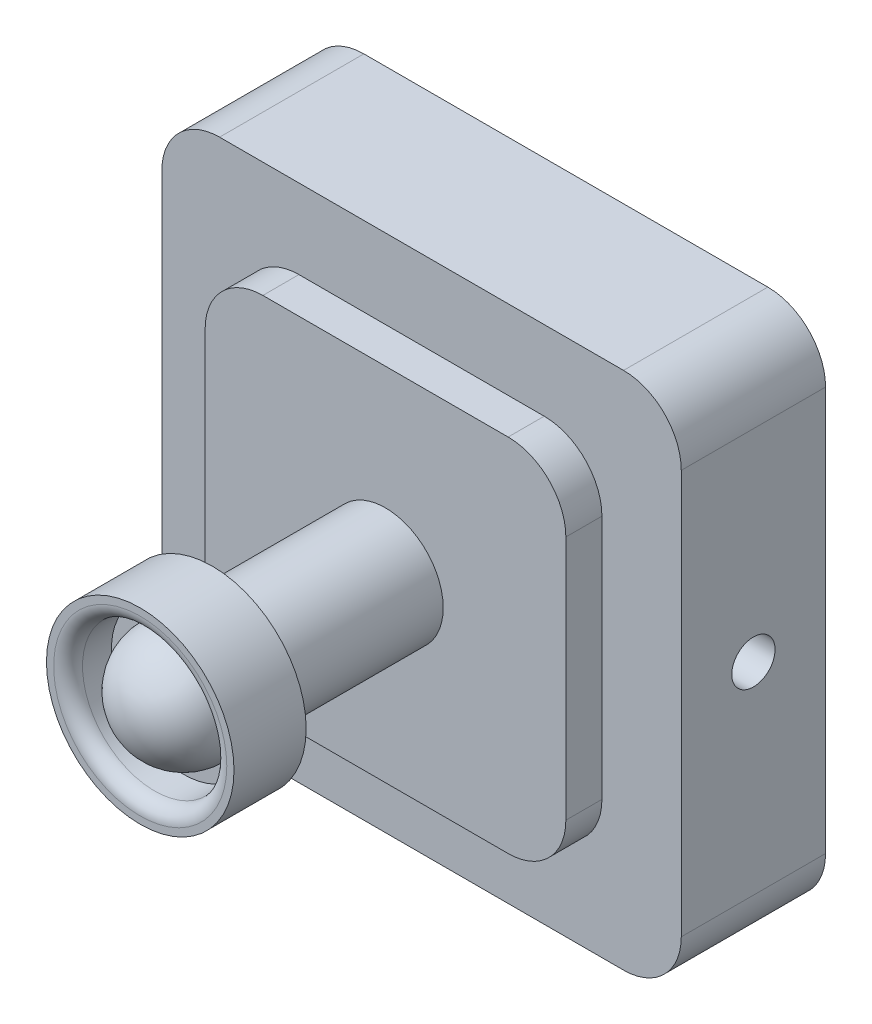
from build123d import *

# Parameters (mm, degrees)
SKETCH1_W           = 36
SKETCH1_H           = 36
BOSS_EXTRUDE1_DEPTH = 10
SKETCH2_W           = 25
SKETCH2_H           = 25
BOSS_EXTRUDE2_DEPTH = 2.5
SKETCH3_R           = 4
BOSS_EXTRUDE3_DEPTH = 12
SKETCH4_R           = 6.5
BOSS_EXTRUDE4_DEPTH = 5
SKETCH5_R           = 5
CUT_EXTRUDE1_DEPTH  = 3
FILLET1_R           = 4
FILLET2_R           = 4
SKETCH7_R           = 1.5
CUT_EXTRUDE2_DEPTH  = 5
SKETCH8_R           = 1.5
CUT_EXTRUDE3_DEPTH  = 5
FILLET3_R           = 1


with BuildPart() as part:
    # Sketch1 → Boss-Extrude1 (new body)
    with BuildSketch(Plane.XY):
        with Locations((18, 18)):
            Rectangle(SKETCH1_W, SKETCH1_H)
    extrude(amount=BOSS_EXTRUDE1_DEPTH)

    # Sketch2 → Boss-Extrude2 (add)
    with BuildSketch(Plane.XY.offset(10)):
        with Locations((18, 18)):
            Rectangle(SKETCH2_W, SKETCH2_H)
    extrude(amount=BOSS_EXTRUDE2_DEPTH)

    # Sketch3 → Boss-Extrude3 (add)
    with BuildSketch(Plane.XY.offset(12.5)):
        with Locations((18, 18)):
            Circle(SKETCH3_R)
    extrude(amount=BOSS_EXTRUDE3_DEPTH)

    # Sketch4 → Boss-Extrude4 (add)
    with BuildSketch(Plane.XY.offset(24.5)):
        with Locations((18, 18)):
            Circle(SKETCH4_R)
    extrude(amount=BOSS_EXTRUDE4_DEPTH)

    # Sketch5 → Cut-Extrude1 (cut)
    with BuildSketch(Plane.XY.offset(29.5)):
        with Locations((18, 18)):
            Circle(SKETCH5_R)
    extrude(amount=-CUT_EXTRUDE1_DEPTH, mode=Mode.SUBTRACT)

    # Sketch6 → Revolve4 (revolve)
    with BuildSketch(Plane.XY.offset(26.5)):
        with BuildLine():
            Line((18, 22), (18, 14))
            ThreePointArc((18, 14), (22, 18), (18, 22))
        make_face()
    revolve(axis=Axis((18, 22, 26.5), (0, -1, 0)))

    # Fillet1
    fillet1_edges = [part.edges().sort_by_distance(p)[0] for p in [
        (30.5, 5.5, 11.25),
        (30.5, 30.5, 11.25),
        (5.5, 30.5, 11.25),
        (5.5, 5.5, 11.25),
    ]]
    fillet(fillet1_edges, radius=FILLET1_R)

    # Fillet2
    fillet2_edges = [part.edges().sort_by_distance(p)[0] for p in [
        (0, 36, 5),
        (36, 36, 5),
        (36, 0, 5),
        (0, 0, 5),
    ]]
    fillet(fillet2_edges, radius=FILLET2_R)

    # Sketch7 → Cut-Extrude2 (cut)
    with BuildSketch(Plane(origin=(36, 0, 0), x_dir=(0, 0, -1), z_dir=(1, 0, 0))):
        with Locations((-5, 18)):
            Circle(SKETCH7_R)
    extrude(amount=-CUT_EXTRUDE2_DEPTH, mode=Mode.SUBTRACT)

    # Sketch8 → Cut-Extrude3 (cut)
    with BuildSketch(Plane.ZY):
        with Locations((5, 18)):
            Circle(SKETCH8_R)
    extrude(amount=-CUT_EXTRUDE3_DEPTH, mode=Mode.SUBTRACT)

    # Fillet3
    fillet3_edges = [part.edges().sort_by_distance(p)[0] for p in [
        (13, 18, 29.5),
    ]]
    fillet(fillet3_edges, radius=FILLET3_R)


solid = part.part
